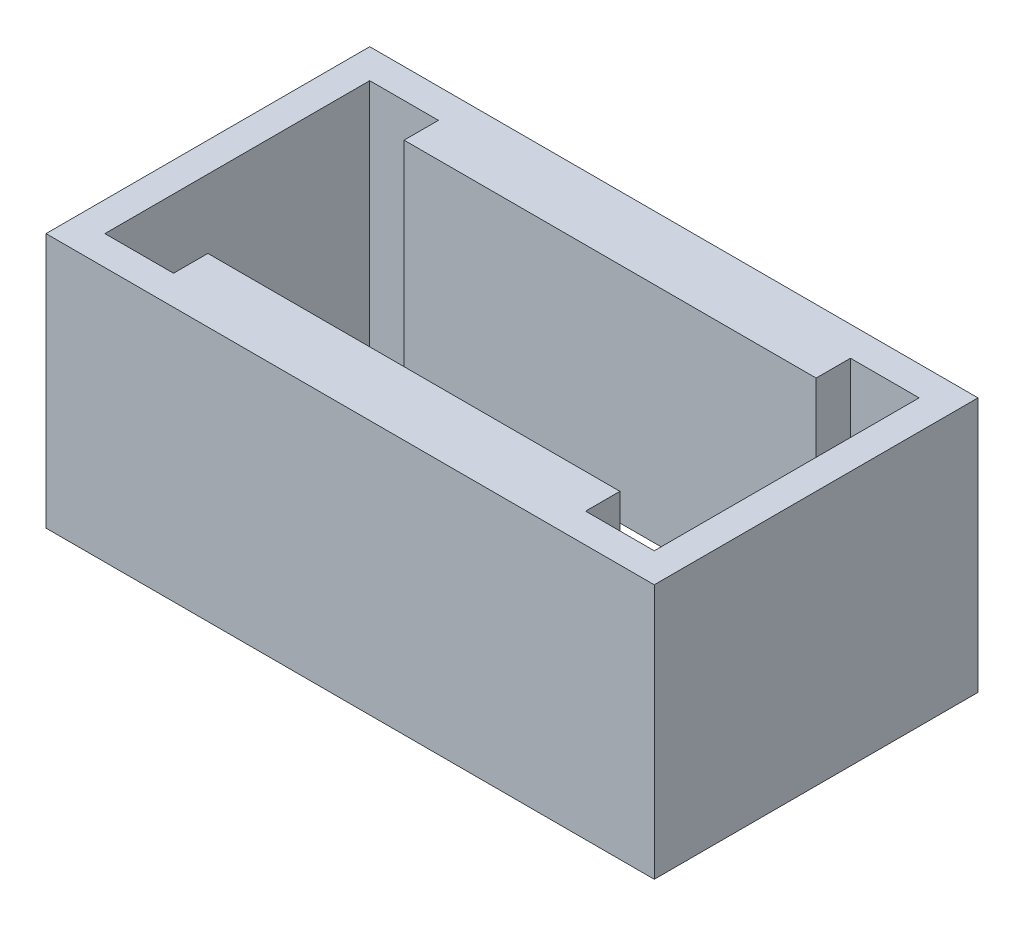
from build123d import *

# Parameters (mm, degrees)
SKETCH1_W           = 31
SKETCH1_H           = 16.5
BOSS_EXTRUDE1_DEPTH = 13
SKETCH2_W           = 21
SKETCH2_H           = 1.75
CUT_EXTRUDE1_DEPTH  = 1.6


with BuildPart() as part:
    # Sketch1 → Boss-Extrude1 (new body)
    with BuildSketch(Plane(origin=(0, 0, 0), x_dir=(1, 0, 0), z_dir=(0, 1, 0))):
        Rectangle(SKETCH1_W, SKETCH1_H)
        Polygon((10.5, 5), (-10.5, 5), (-10.5, 6.75), (-14, 6.75), (-14, -6.75), (-10.5, -6.75), (-10.5, -5), (10.5, -5), (10.5, -6.75), (14, -6.75), (14, 6.75), (10.5, 6.75), align=None, mode=Mode.SUBTRACT)
    extrude(amount=BOSS_EXTRUDE1_DEPTH)

    # Sketch2 → Cut-Extrude1 (cut)
    with BuildSketch(Plane.XZ):
        with Locations((0, 5.875)):
            Rectangle(SKETCH2_W, SKETCH2_H)
        with Locations((0, -5.875)):
            Rectangle(SKETCH2_W, SKETCH2_H)
    extrude(amount=-CUT_EXTRUDE1_DEPTH, mode=Mode.SUBTRACT)


solid = part.part
